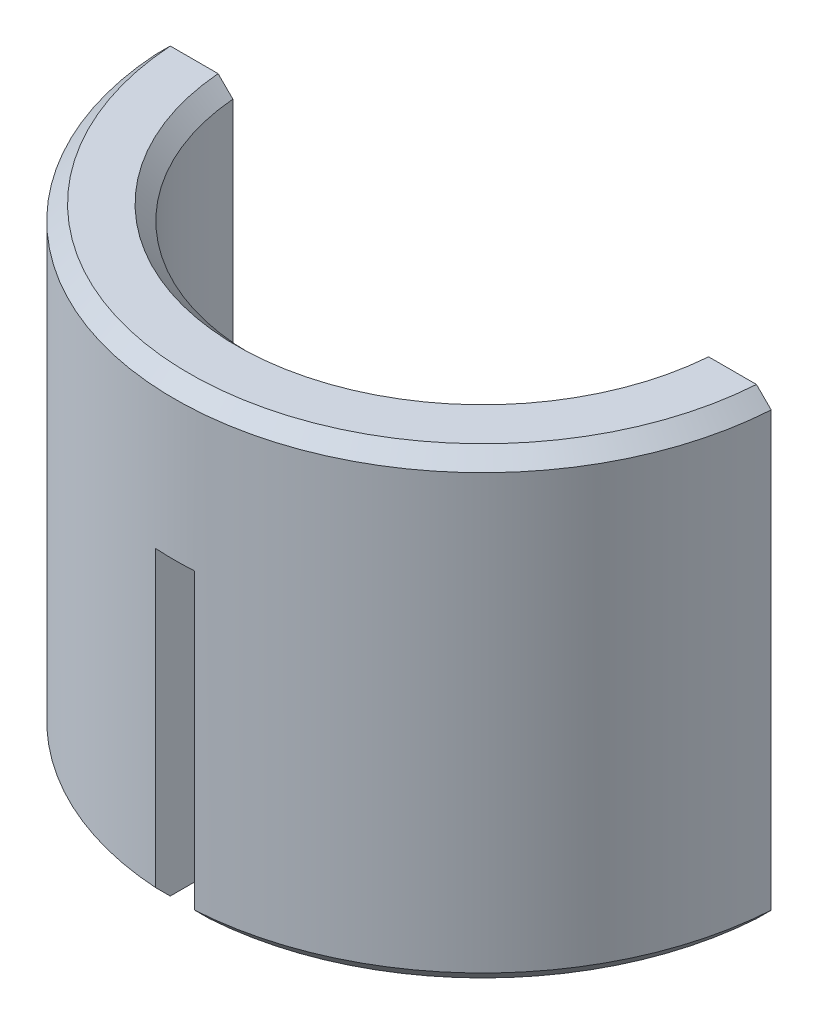
from build123d import *

# Parameters (mm, degrees)
CHAMFER1_SIZE      = 1.35
FILLET1_R          = 0.25
CHAMFER2_SIZE      = 0.381
SKETCH2_W          = 16
SKETCH2_H          = 8.508
CUT_EXTRUDE1_DEPTH = 13
SKETCH3_W          = 1.016
SKETCH3_H          = 8
CUT_EXTRUDE2_DEPTH = 8
SCALE2_SCALE       = 1.001


with BuildPart() as part:
    # Sketch1 → Revolve1 (revolve)
    with BuildSketch(Plane.XY, mode=Mode.PRIVATE) as revolve1_sk:
        Polygon((3.25, 0), (3.25, 2), (6, 2), (6, 12), (8, 12), (8, 0), align=None)
    revolve(revolve1_sk.sketch.rotate(Axis((0, 0, 0), (0, 1, 0)), 90), axis=Axis((0, 0, 0), (0, 1, 0)))  # turned: the seam where the file's is

    # Chamfer1
    chamfer1_edges = [part.edges().sort_by_distance(p)[0] for p in [
        (0, 2, 3.25),
    ]]
    chamfer(chamfer1_edges, length=CHAMFER1_SIZE)

    # Fillet1
    fillet1_edges = [part.edges().sort_by_distance(p)[0] for p in [
        (0, 2, 6),
    ]]
    fillet(fillet1_edges, radius=FILLET1_R)

    # Chamfer2
    chamfer2_edges = [part.edges().sort_by_distance(p)[0] for p in [
        (0, 0, 8),
        (0, 12, 8),
        (0, 12, 6),
    ]]
    chamfer(chamfer2_edges, length=CHAMFER2_SIZE)

    # Sketch2 → Cut-Extrude1 (cut, through all)
    with BuildSketch(Plane(origin=(0, 0, 0), x_dir=(1, 0, 0), z_dir=(0, 1, 0))):
        with Locations((0, 3.746)):
            Rectangle(SKETCH2_W, SKETCH2_H)
    extrude(amount=CUT_EXTRUDE1_DEPTH, mode=Mode.SUBTRACT)

    # Sketch3 → Cut-Extrude2 (cut)
    with BuildSketch(Plane(origin=(0, 0, 0), x_dir=(1, 0, 0), z_dir=(0, 1, 0))):
        with Locations((0, -4)):
            Rectangle(SKETCH3_W, SKETCH3_H)
    extrude(amount=CUT_EXTRUDE2_DEPTH, mode=Mode.SUBTRACT)


with BuildPart() as part_1:
    # Scale2: scaled about (0, 0, 0)
    add(part.part.scale(SCALE2_SCALE))


solid = part_1.part
